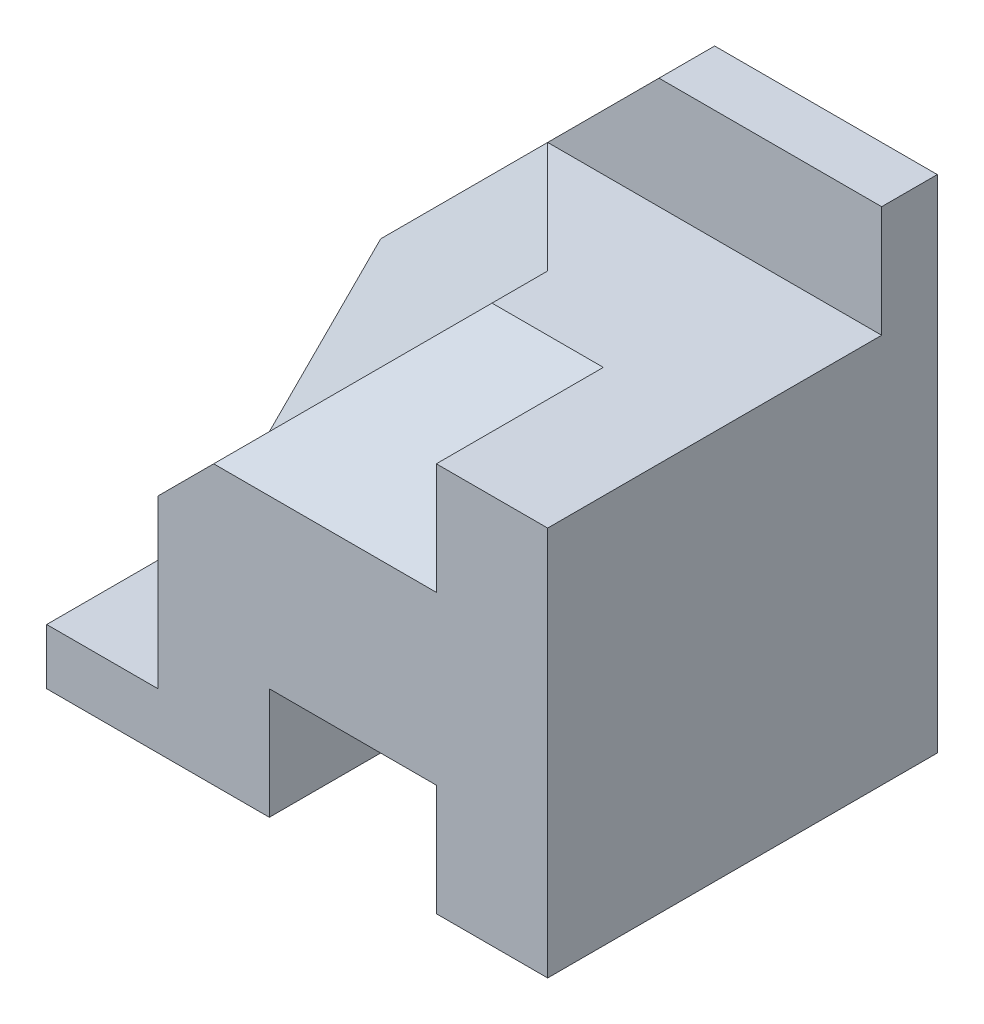
from build123d import *

# Parameters (mm, degrees)
BOSS_EXTRUDE1_DEPTH = 1
SKETCH2_W           = 9
SKETCH2_H           = 7
BOSS_EXTRUDE2_DEPTH = 6
CUT_EXTRUDE1_DEPTH  = 6
SKETCH4_W           = 3
SKETCH4_H           = 2
CUT_EXTRUDE3_DEPTH  = 7
CUT_EXTRUDE5_DEPTH  = 6
CUT_EXTRUDE6_DEPTH  = 6
CUT_EXTRUDE7_DEPTH  = 6


with BuildPart() as part:
    # Sketch1 → Boss-Extrude1 (new body)
    with BuildSketch(Plane.XY):
        Polygon((0, 4), (5, 9), (9, 9), (9, 0), (0, 0), align=None)
    extrude(amount=BOSS_EXTRUDE1_DEPTH)

    # Sketch2 → Boss-Extrude2 (add)
    with BuildSketch(Plane.XY.offset(1)):
        with Locations((4.5, 3.5)):
            Rectangle(SKETCH2_W, SKETCH2_H)
    extrude(amount=BOSS_EXTRUDE2_DEPTH)

    # 3DSketch1 → Cut-Extrude1 (cut, along a direction that is not the sketch's normal)
    with BuildSketch(Plane(origin=(7, 7, 4), x_dir=(-0.7427813527082076, -0.3713906763541037, 0.5570860145311556), z_dir=(0, 0.8320502943378437, 0.554700196225229))):
        Polygon((0, 0), (2.414039396, 2.678136254), (5.385164807, 0), (1.485562705, -1.339068127), align=None)
    extrude(amount=CUT_EXTRUDE1_DEPTH, dir=(0, 1, 0), mode=Mode.SUBTRACT)

    # Sketch4 → Cut-Extrude3 (cut)
    with BuildSketch(Plane.XY.offset(7)):
        with Locations((5.5, 1)):
            Rectangle(SKETCH4_W, SKETCH4_H)
    extrude(amount=-CUT_EXTRUDE3_DEPTH, mode=Mode.SUBTRACT)

    # Sketch5 → Cut-Extrude5 (cut)
    with BuildSketch(Plane(origin=(0, 7, 0), x_dir=(1, 0, 0), z_dir=(0, 1, 0))):
        Polygon((0, -7), (0, -4), (2, -6), (2, -7), align=None)
    extrude(amount=-CUT_EXTRUDE5_DEPTH, mode=Mode.SUBTRACT)

    # 3DSketch4 → Cut-Extrude6 (cut, along a direction that is not the sketch's normal)
    with BuildSketch(Plane(origin=(3, 5, 7), x_dir=(-0.5144957554275265, -0.5144957554275265, -0.6859943405700355), z_dir=(0.7071067811865475, -0.7071067811865476, 0))):
        Polygon((0, 0), (1.028991511, -0.9701425), (1.714985851, -0.242535625), (5.144957554, -0.727606875), (5.830951895, 0), (0.685994341, 4.850712501), (0, 4.123105626), align=None)
    extrude(amount=-CUT_EXTRUDE6_DEPTH, dir=(0, -1, 0), mode=Mode.SUBTRACT)

    # 3DSketch5 → Cut-Extrude7 (cut, along a direction that is not the sketch's normal)
    with BuildSketch(Plane(origin=(0, 2, 3), x_dir=(0.7071067811865476, 0.7071067811865475, 0), z_dir=(-0.577350269189626, 0.577350269189626, 0.5773502691896256))):
        Polygon((0, 0), (1.414213562, 2.449489743), (5.656854249, 2.449489743), (7.071067812, 0), align=None)
    extrude(amount=CUT_EXTRUDE7_DEPTH, dir=(0, 1, 0), mode=Mode.SUBTRACT)


solid = part.part
